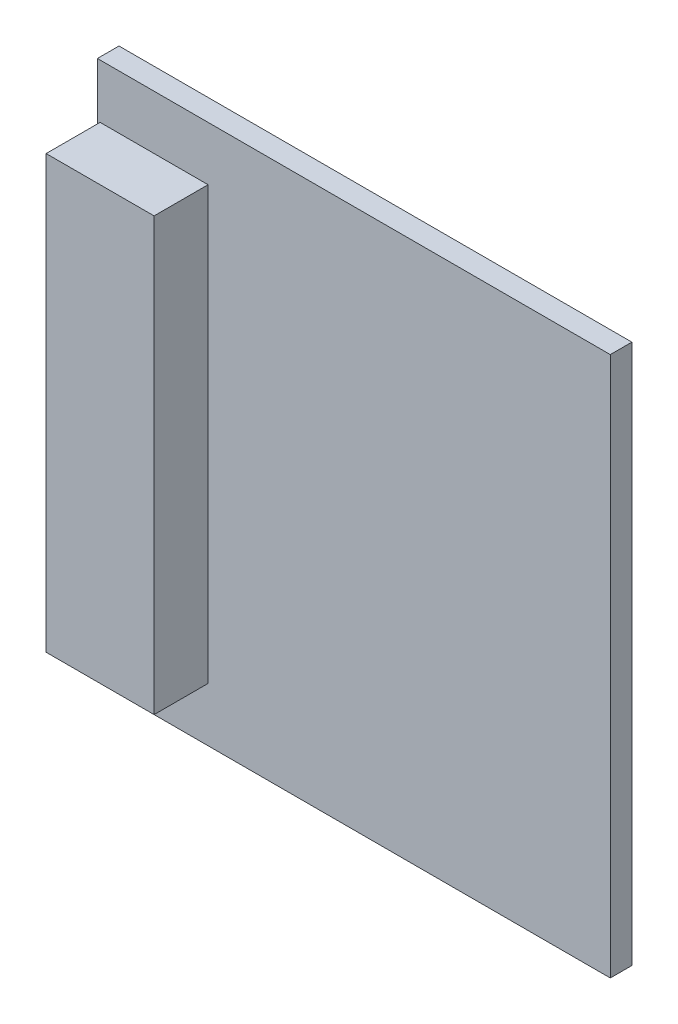
from build123d import *

# Parameters (mm, degrees)
SKETCH1_W           = 24.13
SKETCH1_H           = 25.4
BOSS_EXTRUDE1_DEPTH = 1.016
SKETCH2_W           = 5.08
SKETCH2_H           = 20.32
BOSS_EXTRUDE2_DEPTH = 2.54
SKETCH3_W           = 7.62
SKETCH3_H           = 7.62
BOSS_EXTRUDE3_DEPTH = 3.81
SKETCH5_R           = 3.7465
BOSS_EXTRUDE4_DEPTH = 1.778
SKETCH6_W           = 5.08
SKETCH6_H           = 7.62
BOSS_EXTRUDE5_DEPTH = 1.27


with BuildPart() as part:
    # Sketch1 → Boss-Extrude1 (new body)
    with BuildSketch(Plane.XY):
        Rectangle(SKETCH1_W, SKETCH1_H)
    extrude(amount=BOSS_EXTRUDE1_DEPTH)

    # Sketch3 → Boss-Extrude3 (add)
    with BuildSketch(Plane(origin=(0, 0, 0), x_dir=(-1, 0, 0), z_dir=(0, 0, -1))):
        with Locations((3.175, 0)):
            Rectangle(SKETCH3_W, SKETCH3_H)
    extrude(amount=BOSS_EXTRUDE3_DEPTH)

    # Sketch5 → Boss-Extrude4 (add)
    with BuildSketch(Plane(origin=(0, 0, -3.81), x_dir=(-1, 0, 0), z_dir=(0, 0, -1))):
        with Locations((3.175, 0)):
            Circle(SKETCH5_R)
    extrude(amount=BOSS_EXTRUDE4_DEPTH)

    # Sketch6 → Boss-Extrude5 (add)
    with BuildSketch(Plane(origin=(0, 0, 0), x_dir=(-1, 0, 0), z_dir=(0, 0, -1))):
        with Locations((-8.001, 0)):
            Rectangle(SKETCH6_W, SKETCH6_H)
    extrude(amount=BOSS_EXTRUDE5_DEPTH)


with BuildPart() as body_2:
    # Sketch2 → Boss-Extrude2 (new body)
    with BuildSketch(Plane.XY.offset(1.016)):
        with Locations((-9.398, 0)):
            Rectangle(SKETCH2_W, SKETCH2_H)
    extrude(amount=BOSS_EXTRUDE2_DEPTH)


solid = Compound([part.part, body_2.part])
